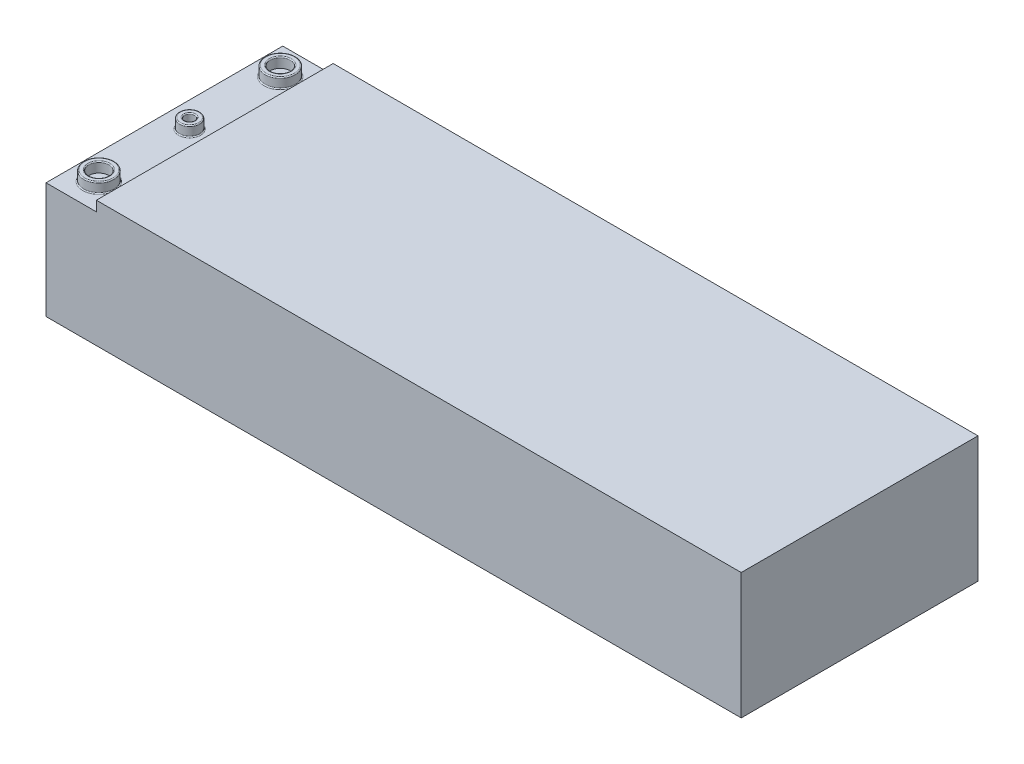
from build123d import *

# Parameters (mm, degrees)
SKETCH1_W           = 138
SKETCH1_H           = 47
BOSS_EXTRUDE1_DEPTH = 25
SKETCH2_W           = 10
SKETCH2_H           = 2
CUT_EXTRUDE1_DEPTH  = 48
SKETCH3_R           = 3
SKETCH3_R_2         = 2
SKETCH3_R_3         = 1
BOSS_EXTRUDE2_DEPTH = 2
FILLET1_R           = 0.2


with BuildPart() as part:
    # Sketch1 → Boss-Extrude1 (new body)
    with BuildSketch(Plane(origin=(0, 0, 0), x_dir=(1, 0, 0), z_dir=(0, 1, 0))):
        Rectangle(SKETCH1_W, SKETCH1_H)
    extrude(amount=BOSS_EXTRUDE1_DEPTH)

    # Sketch2 → Cut-Extrude1 (cut, through all)
    with BuildSketch(Plane.XY.offset(23.5)):
        with Locations((-64, 24)):
            Rectangle(SKETCH2_W, SKETCH2_H)
    extrude(amount=-CUT_EXTRUDE1_DEPTH, mode=Mode.SUBTRACT)

    # Sketch3 → Boss-Extrude2 (add, through all)
    with BuildSketch(Plane(origin=(0, 23, 0), x_dir=(1, 0, 0), z_dir=(0, 1, 0))):
        with Locations((-64, -18)):
            Circle(SKETCH3_R)
        with Locations((-64, -18)):
            Circle(SKETCH3_R_2, mode=Mode.SUBTRACT)
        with Locations((-64, 0)):
            Circle(SKETCH3_R_2)
        with Locations((-64, 0)):
            Circle(SKETCH3_R_3, mode=Mode.SUBTRACT)
        with Locations((-64, 18)):
            Circle(SKETCH3_R)
        with Locations((-64, 18)):
            Circle(SKETCH3_R_2, mode=Mode.SUBTRACT)
    extrude(amount=BOSS_EXTRUDE2_DEPTH)

    # Fillet1
    fillet1_edges = [part.edges().sort_by_distance(p)[0] for p in [
        (-67, 23, 18),
        (-67, 25, 18),
        (-66, 25, 18),
        (-66, 23, 0),
        (-66, 25, 0),
        (-65, 25, 0),
        (-67, 23, -18),
        (-67, 25, -18),
        (-66, 25, -18),
    ]]
    fillet(fillet1_edges, radius=FILLET1_R)


solid = part.part
